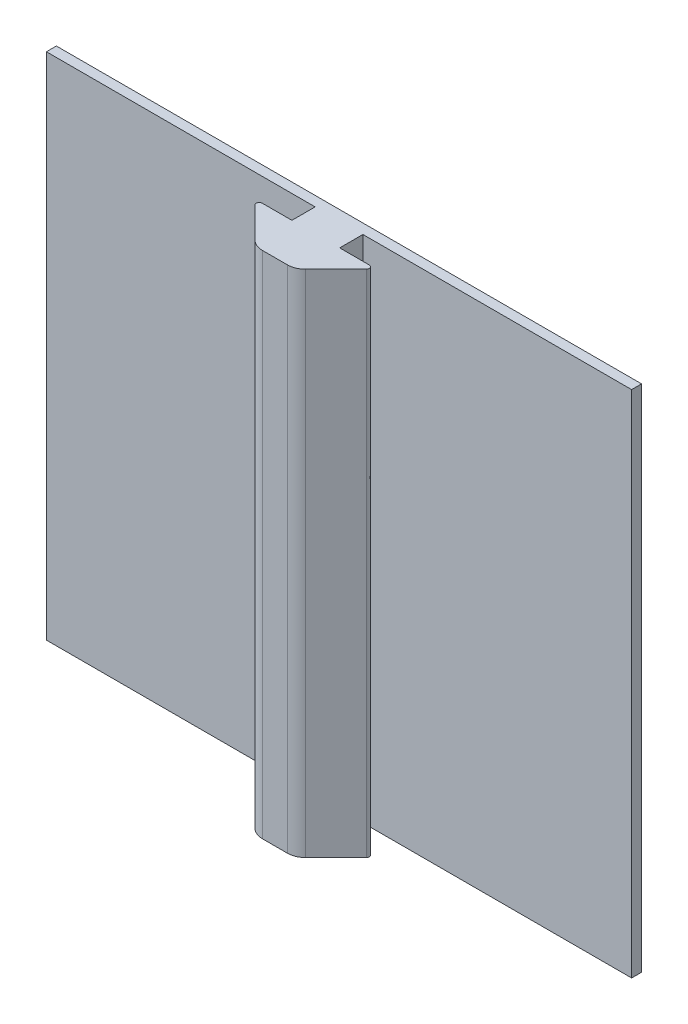
from build123d import *

# Parameters (mm, degrees)
BOSS_EXTRUDE1_DEPTH = 65.024
SKETCH8_R           = 1.524
BOSS_EXTRUDE4_DEPTH = 7.62
SKETCH9_R           = 2.794
BOSS_EXTRUDE5_DEPTH = 3.81


with BuildPart() as part:
    # Sketch2 → Boss-Extrude1 (new body)
    with BuildSketch(Plane(origin=(0, 273.277204506, 0), x_dir=(1, 0, 0), z_dir=(0, 1, 0))):
        with BuildLine():
            Line((-29.45165626, 3.139900531), (-29.45165626, 3.311685007))
            Line((-29.45165626, 3.311685007), (-63.74165626, 3.311685007))
            Line((-63.74165626, 3.311685007), (-63.74165626, 4.581685007))
            Line((-63.74165626, 4.581685007), (10.93434374, 4.581685007))
            Line((10.93434374, 4.581685007), (10.93434374, 3.311685007))
            Line((10.93434374, 3.311685007), (-23.35565626, 3.311685007))
            Line((-23.35565626, 3.311685007), (-23.35565626, 3.139900531))
            Line((-23.35565626, 3.139900531), (-23.35565626, 0.345900531))
            Line((-23.35565626, 0.345900531), (-19.572733097, 0.345900531))
            ThreePointArc((-19.572733097, 0.345900531), (-19.220734995, 0.110702919), (-19.303325413, -0.304507152))
            Line((-19.303325413, -0.304507152), (-23.190363831, -4.19154557))
            ThreePointArc((-23.190363831, -4.19154557), (-23.931995607, -4.68708808), (-24.806809933, -4.861099469))
            Line((-24.806809933, -4.861099469), (-28.000502588, -4.861099469))
            ThreePointArc((-28.000502588, -4.861099469), (-28.875316914, -4.68708808), (-29.616948689, -4.19154557))
            Line((-29.616948689, -4.19154557), (-33.503987108, -0.304507152))
            ThreePointArc((-33.503987108, -0.304507152), (-33.586577526, 0.110702919), (-33.234579424, 0.345900531))
            Line((-33.234579424, 0.345900531), (-29.45165626, 0.345900531))
            Line((-29.45165626, 0.345900531), (-29.45165626, 3.139900531))
        make_face()
    extrude(amount=-BOSS_EXTRUDE1_DEPTH)

    # Sketch8 → Boss-Extrude4 (add)
    with BuildSketch(Plane(origin=(0, 0, -4.581685007), x_dir=(-1, 0, 0), z_dir=(0, 0, -1))):
        with Locations((7.624251866, 262.75164523)):
            Circle(SKETCH8_R)
        with Locations((58.424251866, 247.51164523)):
            Circle(SKETCH8_R)
        with Locations((58.424251866, 219.57164523)):
            Circle(SKETCH8_R)
        with Locations((6.354251866, 214.49164523)):
            Circle(SKETCH8_R)
    extrude(amount=BOSS_EXTRUDE4_DEPTH)

    # Sketch9 → Boss-Extrude5 (add)
    with BuildSketch(Plane(origin=(0, 0, -4.581685007), x_dir=(-1, 0, 0), z_dir=(0, 0, -1))):
        with Locations((7.624251866, 262.75164523)):
            Circle(SKETCH9_R)
        with Locations((58.424251866, 247.51164523)):
            Circle(SKETCH9_R)
        with Locations((6.354251866, 214.49164523)):
            Circle(SKETCH9_R)
        with Locations((58.424251866, 219.57164523)):
            Circle(SKETCH9_R)
    extrude(amount=BOSS_EXTRUDE5_DEPTH)


solid = part.part
